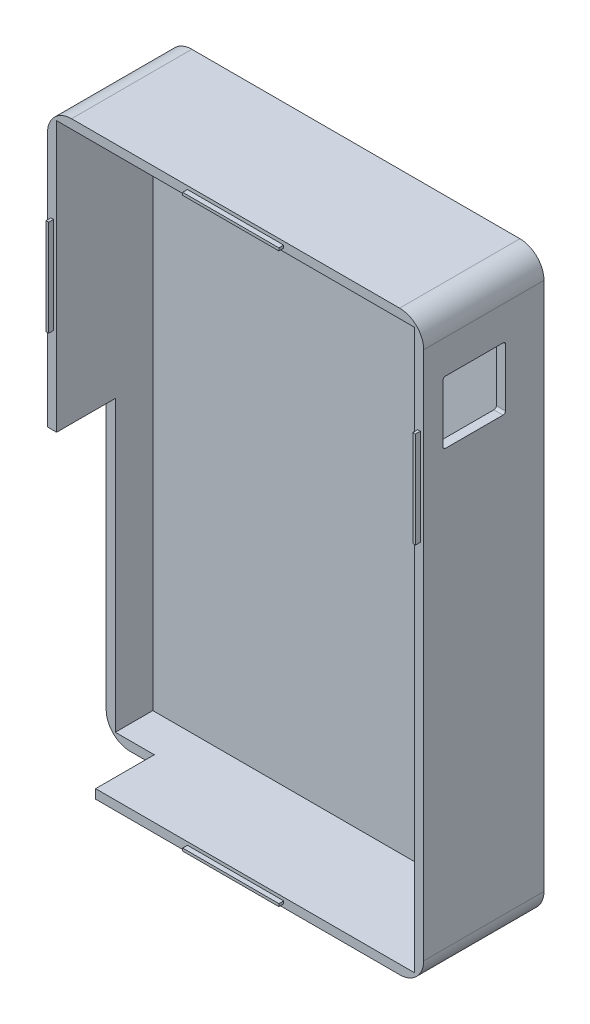
from build123d import *

# Parameters (mm, degrees)
SCHIZZO1_W                   = 78.2
SCHIZZO1_H                   = 120
ESTRUSIONE_ESTRUSIONE1_DEPTH = 5
SCHIZZO2_W                   = 78.2
SCHIZZO2_H                   = 120
SCHIZZO2_W_2                 = 74.4
SCHIZZO2_H_2                 = 116.2
ESTRUSIONE_ESTRUSIONE2_DEPTH = 20
SCHIZZO3_W                   = 0.55
SCHIZZO3_H                   = 20
SCHIZZO3_W_2                 = 20
SCHIZZO3_H_2                 = 0.55
ESTRUSIONE_ESTRUSIONE3_DEPTH = 1
SCHIZZO4_W                   = 13
SCHIZZO4_H                   = 13
TAGLIO_ESTRUSIONE1_DEPTH     = 4
RACCORDO1_R                  = 5
RACCORDO2_R                  = 0.5
SCHIZZO5_W                   = 12.2
SCHIZZO5_H                   = 62
TAGLIO_ESTRUSIONE2_DEPTH     = 10


with BuildPart() as part:
    # Schizzo1 → Estrusione-Estrusione1 (new body)
    with BuildSketch(Plane.XY):
        with Locations((0, -18.836070381)):
            Rectangle(SCHIZZO1_W, SCHIZZO1_H)
    extrude(amount=ESTRUSIONE_ESTRUSIONE1_DEPTH)

    # Schizzo2 → Estrusione-Estrusione2 (add)
    with BuildSketch(Plane.XY.offset(5)):
        with Locations((0, -18.836070381)):
            Rectangle(SCHIZZO2_W, SCHIZZO2_H)
        with Locations((0, -18.836070381)):
            Rectangle(SCHIZZO2_W_2, SCHIZZO2_H_2, mode=Mode.SUBTRACT)
    extrude(amount=ESTRUSIONE_ESTRUSIONE2_DEPTH)

    # Schizzo3 → Estrusione-Estrusione3 (add)
    with BuildSketch(Plane.XY.offset(25)):
        with Locations((-38.125, 11.163929619)):
            Rectangle(SCHIZZO3_W, SCHIZZO3_H)
        with Locations((38.127094898, 11.163929619)):
            Rectangle(SCHIZZO3_W, SCHIZZO3_H)
        with Locations((0, 40.188929619)):
            Rectangle(SCHIZZO3_W_2, SCHIZZO3_H_2)
        with Locations((0, -77.861070381)):
            Rectangle(SCHIZZO3_W_2, SCHIZZO3_H_2)
    extrude(amount=ESTRUSIONE_ESTRUSIONE3_DEPTH)

    # Schizzo4 → Taglio-Estrusione1 (cut)
    with BuildSketch(Plane(origin=(39.1, 0, 0), x_dir=(0, 0, -1), z_dir=(1, 0, 0))):
        with Locations((-14.5, 22.663929619)):
            Rectangle(SCHIZZO4_W, SCHIZZO4_H)
    extrude(amount=-TAGLIO_ESTRUSIONE1_DEPTH, mode=Mode.SUBTRACT)

    # Raccordo1
    raccordo1_edges = [part.edges().sort_by_distance(p)[0] for p in [
        (-39.1, 41.163929619, 12.5),
        (39.1, 41.163929619, 12.5),
        (39.1, -78.836070381, 12.5),
        (-39.1, -78.836070381, 12.5),
    ]]
    fillet(raccordo1_edges, radius=RACCORDO1_R)

    # Raccordo2
    raccordo2_edges = [part.edges().sort_by_distance(p)[0] for p in [
        (38.15, 16.163929619, 21),
        (38.15, 29.163929619, 21),
        (38.15, 29.163929619, 8),
        (38.15, 16.163929619, 8),
    ]]
    fillet(raccordo2_edges, radius=RACCORDO2_R)

    # Schizzo5 → Taglio-Estrusione2 (cut)
    with BuildSketch(Plane.ZY.offset(39.1)):
        with Locations((18.9, -47.836070381)):
            Rectangle(SCHIZZO5_W, SCHIZZO5_H)
    extrude(amount=-TAGLIO_ESTRUSIONE2_DEPTH, mode=Mode.SUBTRACT)


solid = part.part
